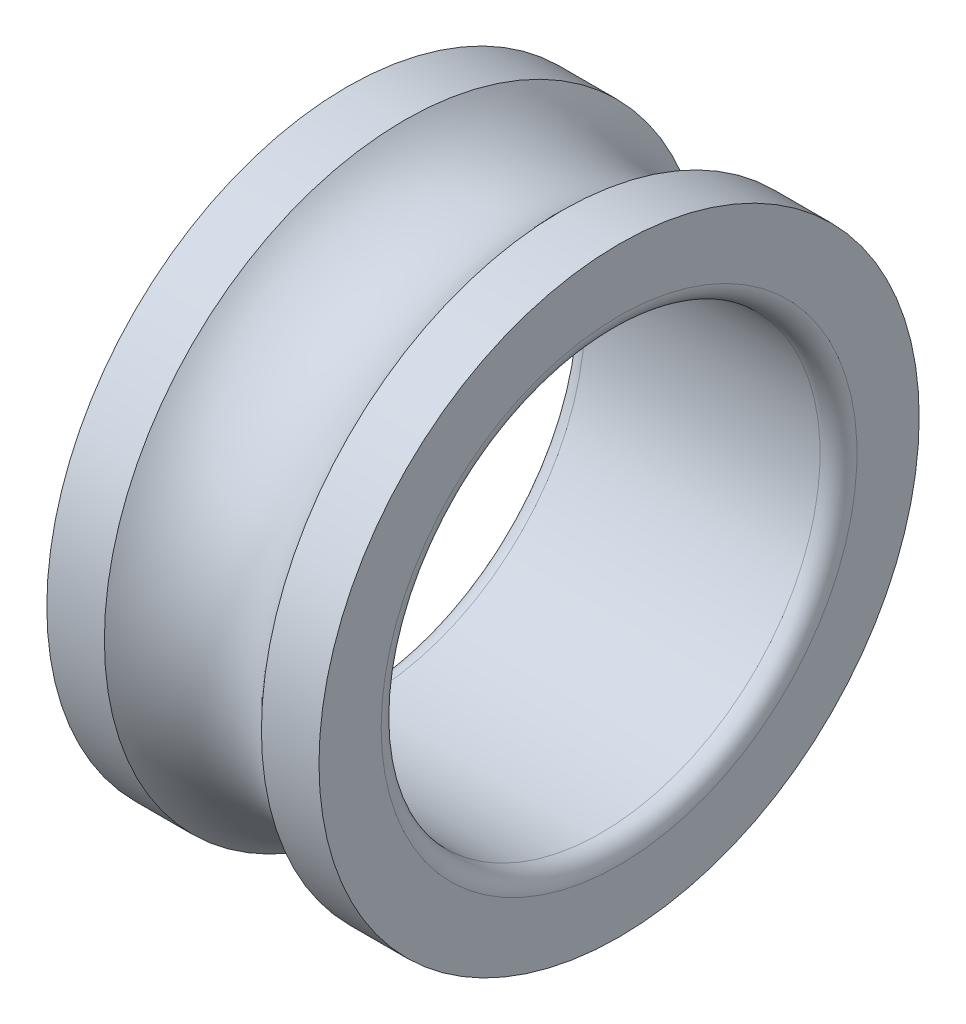
from build123d import *


with BuildPart() as part:
    # Sketch2 → Revolve1 (revolve)
    with BuildSketch(Plane.XY):
        with BuildLine():
            Line((8.94427191, 34.185185185), (15.5, 34.185185185))
            Line((15.5, 34.185185185), (15.5, 27.1))
            ThreePointArc((15.5, 27.1), (14.88492424, 25.61507576), (13.4, 25))
            Line((13.4, 25), (-13.4, 25))
            ThreePointArc((-13.4, 25), (-14.88492424, 25.61507576), (-15.5, 27.1))
            Line((-15.5, 27.1), (-15.5, 34.185185185))
            Line((-15.5, 34.185185185), (-8.94427191, 34.185185185))
            ThreePointArc((-8.94427191, 34.185185185), (0, 30.185185185), (8.94427191, 34.185185185))
        make_face()
    revolve(axis=Axis((-14.280092593, 0, 0), (1, 0, 0)))


solid = part.part
